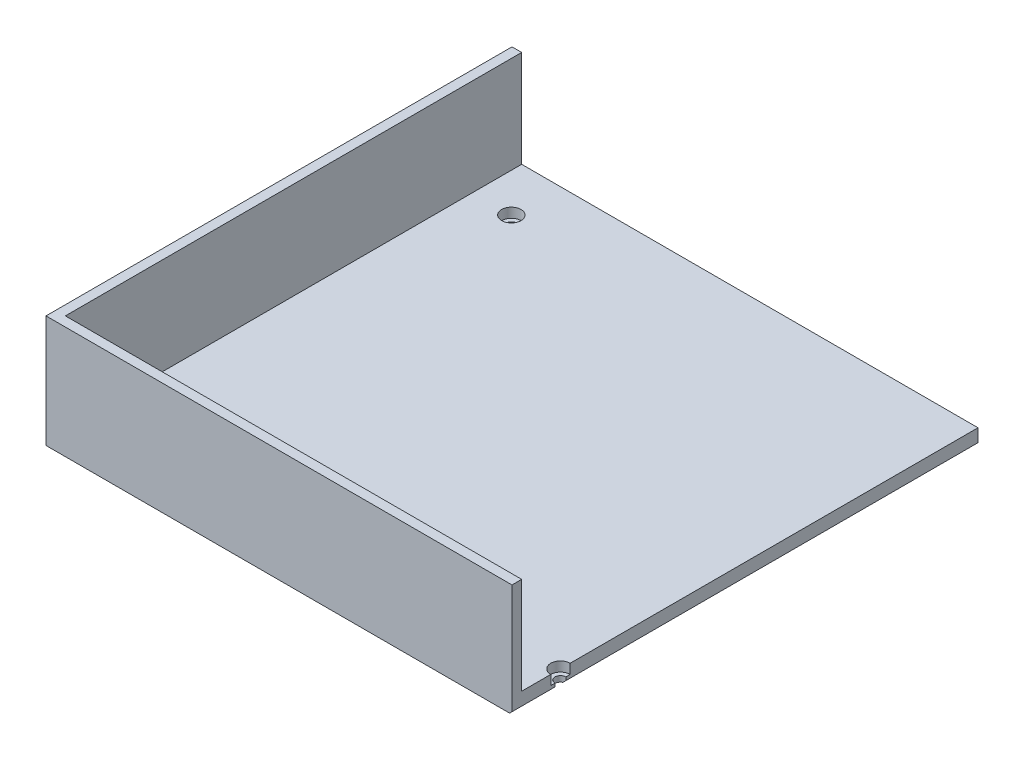
from build123d import *

# Parameters (mm, degrees)
SKETCH1_W                      = 192.4
SKETCH1_H                      = 192.4
BOSS_EXTRUDE1_DEPTH            = 6.35
BOSS_EXTRUDE2_DEPTH            = 40
CBORE_FOR_M4_SHCS1_D           = 4.5
CBORE_FOR_M4_SHCS1_DEPTH       = 6.35
CBORE_FOR_M4_SHCS1_CBORE_D     = 8
CBORE_FOR_M4_SHCS1_CBORE_DEPTH = 4
CHAMFER1_SIZE                  = 1


with BuildPart() as part:
    # Sketch1 → Boss-Extrude1 (new body)
    with BuildSketch(Plane(origin=(0, 0, 0), x_dir=(1, 0, 0), z_dir=(0, 1, 0))):
        Rectangle(SKETCH1_W, SKETCH1_H)
    extrude(amount=BOSS_EXTRUDE1_DEPTH)

    # Sketch2 → Boss-Extrude2 (add)
    with BuildSketch(Plane(origin=(0, 6.35, 0), x_dir=(1, 0, 0), z_dir=(0, 1, 0))):
        Polygon((-92.2, 92.2), (-92.2, -92.2), (92.2, -92.2), (96.2, -92.2), (96.2, -96.2), (-96.2, -96.2), (-96.2, 96.2), (-92.2, 96.2), align=None)
    extrude(amount=BOSS_EXTRUDE2_DEPTH)

    # CBORE for M4 SHCS1
    with Locations(Plane(origin=(0, 6.35, 0), x_dir=(1, 0, 0), z_dir=(0, 1, 0))):
        with Locations((96.2, -76.2), (-76.2, -76.2), (-76.2, 75.92365398)):
            CounterBoreHole(CBORE_FOR_M4_SHCS1_D / 2, CBORE_FOR_M4_SHCS1_CBORE_D / 2, CBORE_FOR_M4_SHCS1_CBORE_DEPTH, depth=CBORE_FOR_M4_SHCS1_DEPTH)

    # Chamfer1
    chamfer1_edges = [part.edges().sort_by_distance(p)[0] for p in [
        (96.2, 0, -11.125),
        (0, 0, -96.2),
        (96.2, 0, 87.325),
    ]]
    chamfer(chamfer1_edges, length=CHAMFER1_SIZE)


solid = part.part
